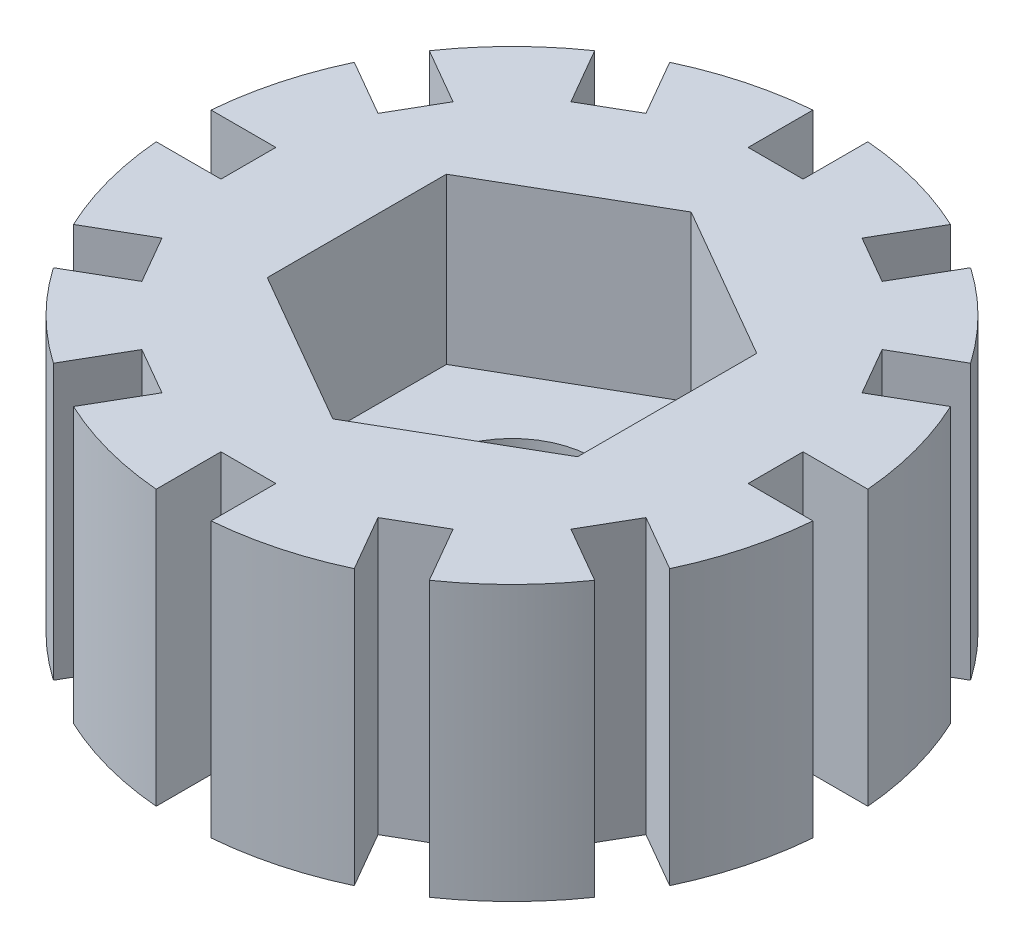
from build123d import *

# Parameters (mm, degrees)
SKETCH1_R           = 6
SKETCH1_R_2         = 1.5
BOSS_EXTRUDE1_DEPTH = 5
CUT_EXTRUDE1_DEPTH  = 3
SKETCH7_W           = 1
SKETCH7_H           = 7.146818719
CUT_EXTRUDE2_DEPTH  = 10
CIRPATTERN1_COUNT   = 12


with BuildPart() as part:
    # Sketch1 → Boss-Extrude1 (new body)
    with BuildSketch(Plane(origin=(0, 0, 0), x_dir=(1, 0, 0), z_dir=(0, 1, 0))):
        Circle(SKETCH1_R)
        Circle(SKETCH1_R_2, mode=Mode.SUBTRACT)
    extrude(amount=BOSS_EXTRUDE1_DEPTH)

    # Sketch6 → Cut-Extrude1 (cut)
    with BuildSketch(Plane(origin=(0, 5, 0), x_dir=(1, 0, 0), z_dir=(0, 1, 0))):
        Polygon((2.825, -1.63101451), (2.825, 1.63101451), (0, 3.262029021), (-2.825, 1.63101451), (-2.825, -1.63101451), (0, -3.262029021), align=None)
    extrude(amount=-CUT_EXTRUDE1_DEPTH, mode=Mode.SUBTRACT)

    # Sketch7 → Cut-Extrude2 (cut)
    with BuildSketch(Plane(origin=(0, 5, 0), x_dir=(1, 0, 0), z_dir=(0, 1, 0))):
        with Locations((0, 8.37340936)):
            Rectangle(SKETCH7_W, SKETCH7_H)
    cut_extrude2 = extrude(amount=-CUT_EXTRUDE2_DEPTH, mode=Mode.SUBTRACT)

    # CirPattern1: Cut-Extrude2 ×12 about axis
    cirpattern1_axis = Axis((0, 0, 0), (0, 1, 0))
    for i in range(1, CIRPATTERN1_COUNT):
        add(cut_extrude2.rotate(cirpattern1_axis, i * 360 / CIRPATTERN1_COUNT), mode=Mode.SUBTRACT)


solid = part.part
